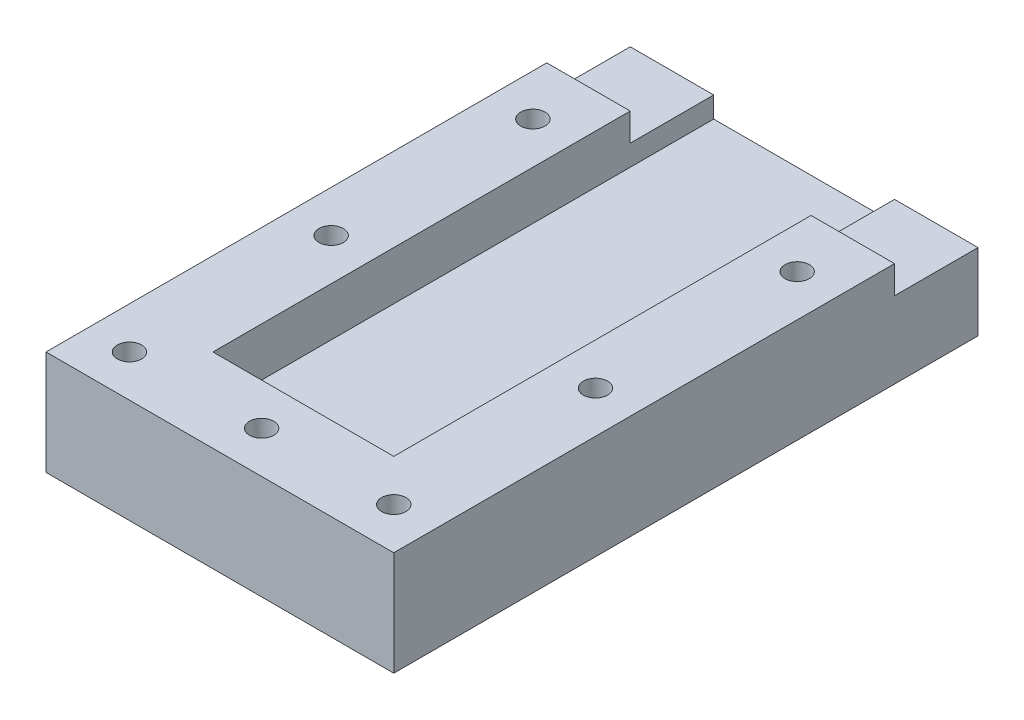
from build123d import *

# Parameters (mm, degrees)
SKETCH_1_W          = 50
SKETCH_1_H          = 30
EXTRUDE_1_DEPTH     = 84
SKETCH_2_W          = 26
SKETCH_2_H          = 14
CUT_EXTRUDE_1_DEPTH = 72
SKETCH_5_W          = 12
SKETCH_5_H          = 8
CUT_EXTRUDE_4_DEPTH = 94.407708461
SKETCH_6_W          = 12
SKETCH_6_H          = 8
CUT_EXTRUDE_5_DEPTH = 94.407708461
SKETCH_7_R          = 1.75
CUT_EXTRUDE_6_DEPTH = 93.633687177


with BuildPart() as part:
    # ｽｹｯﾁ1 → ﾎﾞｽ - 押し出し1 (new body)
    with BuildSketch(Plane.XY):
        Rectangle(SKETCH_1_W, SKETCH_1_H)
    extrude(amount=EXTRUDE_1_DEPTH)

    # ｽｹｯﾁ2 → ｶｯﾄ - 押し出し1 (cut)
    with BuildSketch(Plane(origin=(0, 0, 0), x_dir=(-1, 0, 0), z_dir=(0, 0, -1))):
        Rectangle(SKETCH_2_W, SKETCH_2_H)
    extrude(amount=-CUT_EXTRUDE_1_DEPTH, mode=Mode.SUBTRACT)

    # ｽｹｯﾁ5 → ｶｯﾄ - 押し出し4 (cut, through all)
    with BuildSketch(Plane.ZY.offset(-13)):
        with Locations((6, 0)):
            Rectangle(SKETCH_5_W, SKETCH_5_H)
    extrude(amount=-CUT_EXTRUDE_4_DEPTH, mode=Mode.SUBTRACT)

    # ｽｹｯﾁ6 → ｶｯﾄ - 押し出し5 (cut, through all)
    with BuildSketch(Plane(origin=(-13, 0, 0), x_dir=(0, 0, -1), z_dir=(1, 0, 0))):
        with Locations((-6, 0)):
            Rectangle(SKETCH_6_W, SKETCH_6_H)
    extrude(amount=-CUT_EXTRUDE_5_DEPTH, mode=Mode.SUBTRACT)

    # ｽｹｯﾁ7 → ｶｯﾄ - 押し出し6 (cut, through all)
    with BuildSketch(Plane(origin=(0, 15, 0), x_dir=(1, 0, 0), z_dir=(0, 1, 0))):
        with Locations(Location((19, -20, 0), (0, 0, 270))):
            Circle(SKETCH_7_R)
        with Locations(Location((19, -49, 0), (0, 0, 270))):
            Circle(SKETCH_7_R)
        with Locations(Location((19, -78, 0), (0, 0, 270))):
            Circle(SKETCH_7_R)
        with Locations(Location((0, -78, 0), (0, 0, 270))):
            Circle(SKETCH_7_R)
        with Locations(Location((-19, -78, 0), (0, 0, 270))):
            Circle(SKETCH_7_R)
        with Locations(Location((-19, -49, 0), (0, 0, 270))):
            Circle(SKETCH_7_R)
        with Locations(Location((-19, -20, 0), (0, 0, 270))):
            Circle(SKETCH_7_R)
    extrude(amount=-CUT_EXTRUDE_6_DEPTH, mode=Mode.SUBTRACT)

    # Surface Cut 1
    split(bisect_by=Plane(origin=(0, 0, 0), x_dir=(-1, 0, 0), z_dir=(0, -1, 0)), keep=Keep.TOP)


solid = part.part
